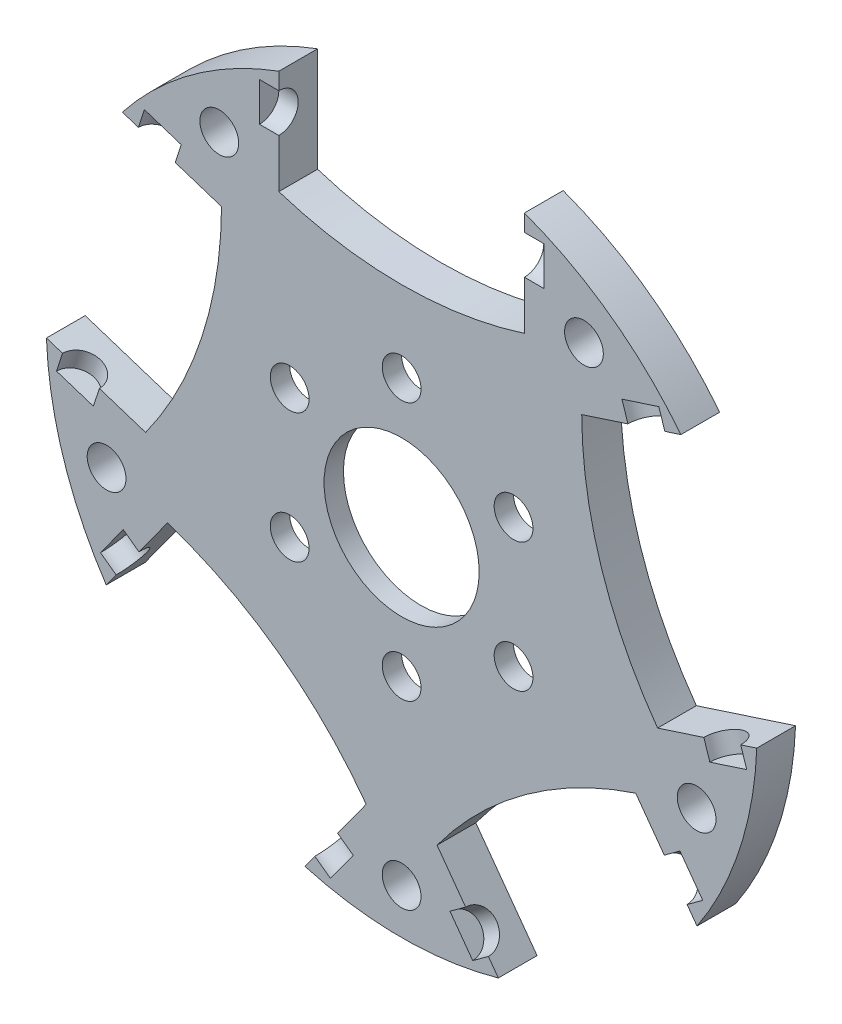
from build123d import *

# Parameters (mm, degrees)
BOSS_EXTRUDE1_DEPTH = 3
SKETCH2_R           = 1.5
SKETCH2_R_2         = 6
CUT_EXTRUDE1_DEPTH  = 3
SKETCH5_W           = 22
SKETCH5_H           = 1.5
CIRPATTERN1_COUNT   = 5
SKETCH6_R           = 14
CUT_EXTRUDE2_DEPTH  = 1.5


with BuildPart() as part:
    # Sketch1 → Boss-Extrude1 (new body)
    with BuildSketch(Plane.XY):
        with BuildLine():
            Line((-9.5, 25.806975801), (-9.5, 17.737494192))
            ThreePointArc((-9.5, 17.737494192), (0, 16.25), (9.5, 17.737494192))
            Line((9.5, 17.737494192), (9.5, 25.806975801))
            ThreePointArc((9.5, 25.806975801), (16.164094438, 22.247967345), (21.608231055, 17.009831001))
            Line((21.608231055, 17.009831001), (13.933697987, 14.516224048))
            ThreePointArc((13.933697987, 14.516224048), (15.45466839, 5.021526159), (19.805020881, -3.553849762))
            Line((19.805020881, -3.553849762), (27.479553948, -1.060242809))
            ThreePointArc((27.479553948, -1.060242809), (26.154054198, -8.497967345), (22.854621229, -15.2943221))
            Line((22.854621229, -15.2943221), (18.111498945, -8.765974342))
            ThreePointArc((18.111498945, -8.765974342), (9.55151035, -13.146526159), (2.740176052, -19.933894136))
            Line((2.740176052, -19.933894136), (7.483298336, -26.462241893))
            ThreePointArc((7.483298336, -26.462241893), (0, -27.5), (-7.483298336, -26.462241893))
            Line((-7.483298336, -26.462241893), (-2.740176052, -19.933894136))
            ThreePointArc((-2.740176052, -19.933894136), (-9.55151035, -13.146526159), (-18.111498945, -8.765974342))
            Line((-18.111498945, -8.765974342), (-22.854621229, -15.2943221))
            ThreePointArc((-22.854621229, -15.2943221), (-26.154054198, -8.497967345), (-27.479553948, -1.060242809))
            Line((-27.479553948, -1.060242809), (-19.805020881, -3.553849762))
            ThreePointArc((-19.805020881, -3.553849762), (-15.45466839, 5.021526159), (-13.933697987, 14.516224048))
            Line((-13.933697987, 14.516224048), (-21.608231055, 17.009831001))
            ThreePointArc((-21.608231055, 17.009831001), (-16.164094438, 22.247967345), (-9.5, 25.806975801))
        make_face()
    extrude(amount=BOSS_EXTRUDE1_DEPTH)

    # Sketch2 → Cut-Extrude1 (cut)
    with BuildSketch(Plane.XY.offset(3)):
        with Locations((0, 10)):
            Circle(SKETCH2_R)
        with Locations((-8.660254038, 5)):
            Circle(SKETCH2_R)
        with Locations((-8.660254038, -5)):
            Circle(SKETCH2_R)
        with Locations((0, -10)):
            Circle(SKETCH2_R)
        with Locations((8.660254038, -5)):
            Circle(SKETCH2_R)
        with Locations((8.660254038, 5)):
            Circle(SKETCH2_R)
        Circle(SKETCH2_R_2)
        with Locations((14.106846055, 19.416407865)):
            Circle(SKETCH2_R)
        with Locations((22.825356391, -7.416407865)):
            Circle(SKETCH2_R)
        with Locations((0, -24)):
            Circle(SKETCH2_R)
        with Locations((-22.825356391, -7.416407865)):
            Circle(SKETCH2_R)
        with Locations((-14.106846055, 19.416407865)):
            Circle(SKETCH2_R)
    extrude(amount=-CUT_EXTRUDE1_DEPTH, mode=Mode.SUBTRACT)

    # Sketch5 → Cut-Revolve1 (revolve, cut)
    with BuildSketch(Plane.XY.offset(3)):
        with Locations((0, 23.75)):
            Rectangle(SKETCH5_W, SKETCH5_H)
    cut_revolve1 = revolve(axis=Axis((-11, 23, 3), (1, 0, 0)), mode=Mode.SUBTRACT)

    # CirPattern1: Cut-Revolve1 ×5 about axis
    cirpattern1_axis = Axis((0, 0, 0), (0, 0, 1))
    for i in range(1, CIRPATTERN1_COUNT):
        add(cut_revolve1.rotate(cirpattern1_axis, i * 360 / CIRPATTERN1_COUNT), mode=Mode.SUBTRACT)

    # Sketch6 → Cut-Extrude2 (cut)
    with BuildSketch(Plane(origin=(0, 0, 0), x_dir=(-1, 0, 0), z_dir=(0, 0, -1))):
        Circle(SKETCH6_R)
    extrude(amount=-CUT_EXTRUDE2_DEPTH, mode=Mode.SUBTRACT)


solid = part.part
